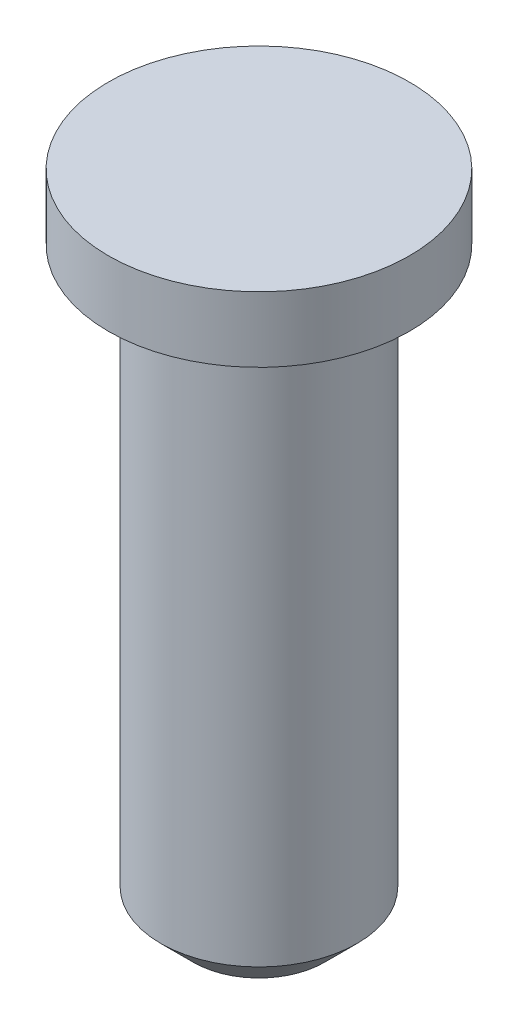
from build123d import *

# Parameters (mm, degrees)
CHAFL_N1_SIZE = 0.5


with BuildPart() as part:
    # Croquis1 → Revolución1 (revolve)
    with BuildSketch(Plane.XY):
        Polygon((0, 0), (2.3, 0), (2.3, -1), (1.5, -1), (1.5, -10), (0, -10), align=None)
    revolve(axis=Axis((0, 0, 0), (0, -1, 0)))

    # Chaflán1
    chafl_n1_edges = [part.edges().sort_by_distance(p)[0] for p in [
        (-1.5, -10, 0),
    ]]
    chamfer(chafl_n1_edges, length=CHAFL_N1_SIZE)


solid = part.part
